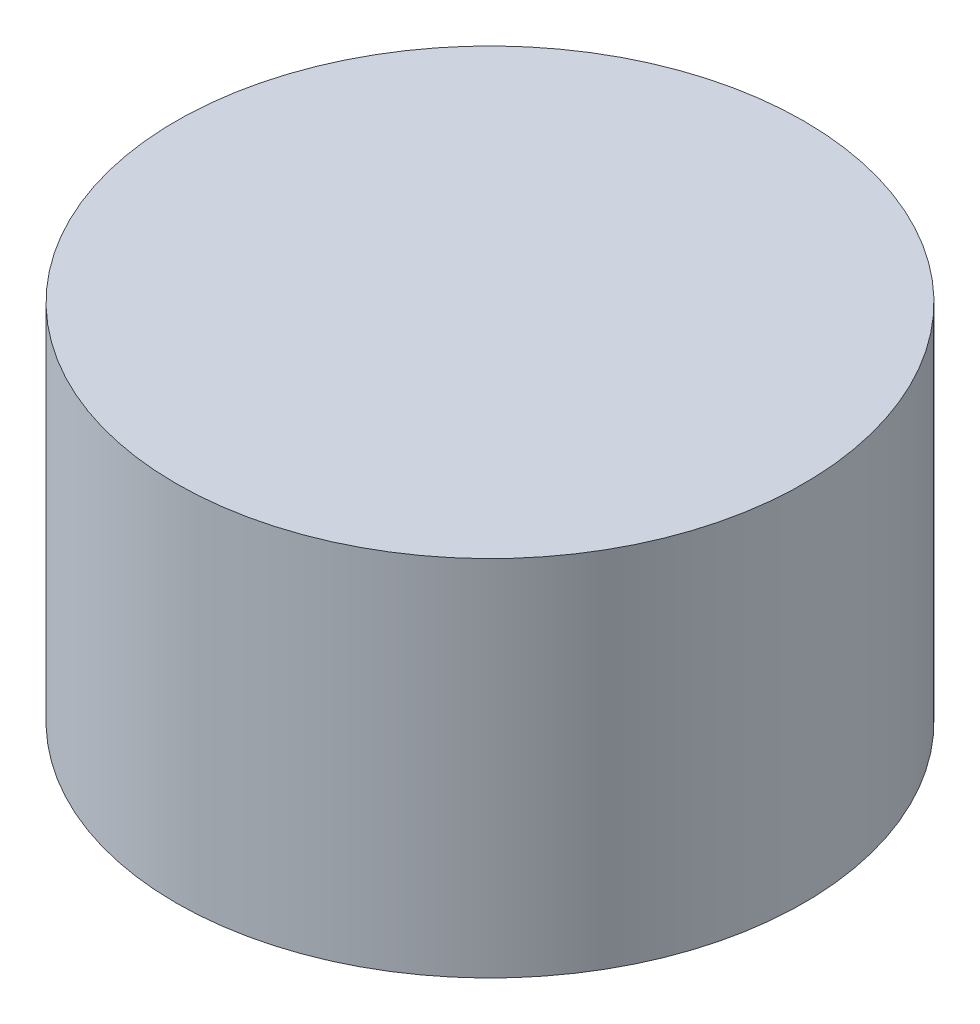
from build123d import *

# Parameters (mm, degrees)
SKETCH1_R           = 60.5
BOSS_EXTRUDE1_DEPTH = 70


with BuildPart() as part:
    # Sketch1 → Boss-Extrude1 (new body)
    with BuildSketch(Plane(origin=(0, 0, 0), x_dir=(1, 0, 0), z_dir=(0, 1, 0))):
        Circle(SKETCH1_R)
    extrude(amount=BOSS_EXTRUDE1_DEPTH)


solid = part.part
